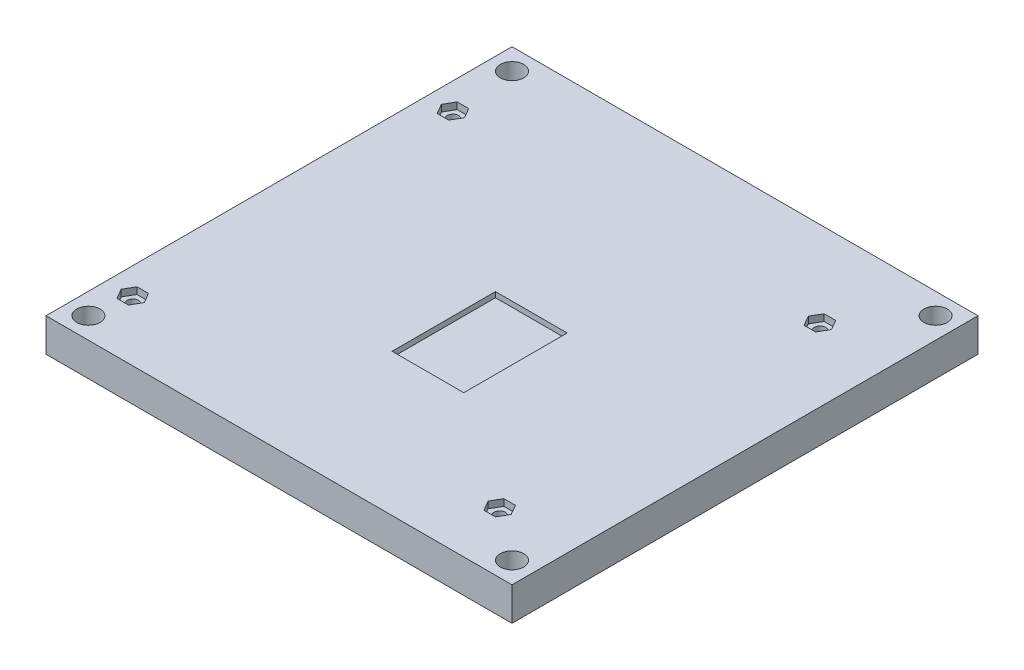
from build123d import *

# Parameters (mm, degrees)
SKETCH2_W           = 139.7
SKETCH2_H           = 139.7
BOSS_EXTRUDE1_DEPTH = 10
SKETCH1_R           = 3.5
CUT_EXTRUDE1_DEPTH  = 10
SKETCH3_W           = 21.5
SKETCH3_H           = 31
CUT_EXTRUDE2_DEPTH  = 1.6
SKETCH4_R           = 1.7
CUT_EXTRUDE3_DEPTH  = 10
CUT_EXTRUDE4_DEPTH  = 2


with BuildPart() as part:
    # Sketch2 → Boss-Extrude1 (new body)
    with BuildSketch(Plane(origin=(0, 0, 0), x_dir=(1, 0, 0), z_dir=(0, 1, 0))):
        with Locations((69.85, 69.85)):
            Rectangle(SKETCH2_W, SKETCH2_H)
    extrude(amount=BOSS_EXTRUDE1_DEPTH)

    # Sketch1 → Cut-Extrude1 (cut)
    with BuildSketch(Plane(origin=(0, 10, 0), x_dir=(1, 0, 0), z_dir=(0, 1, 0))):
        with BuildLine():
            Line((6.35, 136.85), (6.35, 133.35))
            Line((6.35, 133.35), (2.85, 133.35))
            ThreePointArc((2.85, 133.35), (6.35, 129.85), (9.85, 133.35))
            ThreePointArc((9.85, 133.35), (8.824873734, 135.824873734), (6.35, 136.85))
        make_face()
        with BuildLine():
            Line((2.85, 133.35), (6.35, 133.35))
            Line((6.35, 133.35), (6.35, 136.85))
            ThreePointArc((6.35, 136.85), (3.875126266, 135.824873734), (2.85, 133.35))
        make_face()
        with Locations((133.35, 133.35)):
            Circle(SKETCH1_R)
        with Locations((6.35, 6.35)):
            Circle(SKETCH1_R)
        with Locations((133.35, 6.35)):
            Circle(SKETCH1_R)
    extrude(amount=-CUT_EXTRUDE1_DEPTH, mode=Mode.SUBTRACT)

    # Sketch3 → Cut-Extrude2 (cut)
    with BuildSketch(Plane(origin=(0, 10, 0), x_dir=(1, 0, 0), z_dir=(0, 1, 0))):
        with Locations((71.85, 58.1468)):
            Rectangle(SKETCH3_W, SKETCH3_H)
    extrude(amount=-CUT_EXTRUDE2_DEPTH, mode=Mode.SUBTRACT)

    # Sketch4 → Cut-Extrude3 (cut)
    with BuildSketch(Plane(origin=(0, 10, 0), x_dir=(1, 0, 0), z_dir=(0, 1, 0))):
        with Locations((7.85, 114.1468)):
            Circle(SKETCH4_R)
        with Locations((7.85, 18.1468)):
            Circle(SKETCH4_R)
        with Locations((117.85, 114.1468)):
            Circle(SKETCH4_R)
        with Locations((117.85, 18.1468)):
            Circle(SKETCH4_R)
    extrude(amount=-CUT_EXTRUDE3_DEPTH, mode=Mode.SUBTRACT)

    # Sketch5 → Cut-Extrude4 (cut)
    with BuildSketch(Plane(origin=(0, 10, 0), x_dir=(1, 0, 0), z_dir=(0, 1, 0))):
        Polygon((9.582050808, 111.1468), (11.314101615, 114.1468), (9.582050808, 117.1468), (6.117949192, 117.1468), (4.385898385, 114.1468), (6.117949192, 111.1468), align=None)
        Polygon((9.582050808, 15.1468), (11.314101615, 18.1468), (9.582050808, 21.1468), (6.117949192, 21.1468), (4.385898385, 18.1468), (6.117949192, 15.1468), align=None)
        Polygon((119.582050808, 111.1468), (121.314101615, 114.1468), (119.582050808, 117.1468), (116.117949192, 117.1468), (114.385898385, 114.1468), (116.117949192, 111.1468), align=None)
        Polygon((119.582050808, 15.1468), (121.314101615, 18.1468), (119.582050808, 21.1468), (116.117949192, 21.1468), (114.385898385, 18.1468), (116.117949192, 15.1468), align=None)
    extrude(amount=-CUT_EXTRUDE4_DEPTH, mode=Mode.SUBTRACT)


solid = part.part
